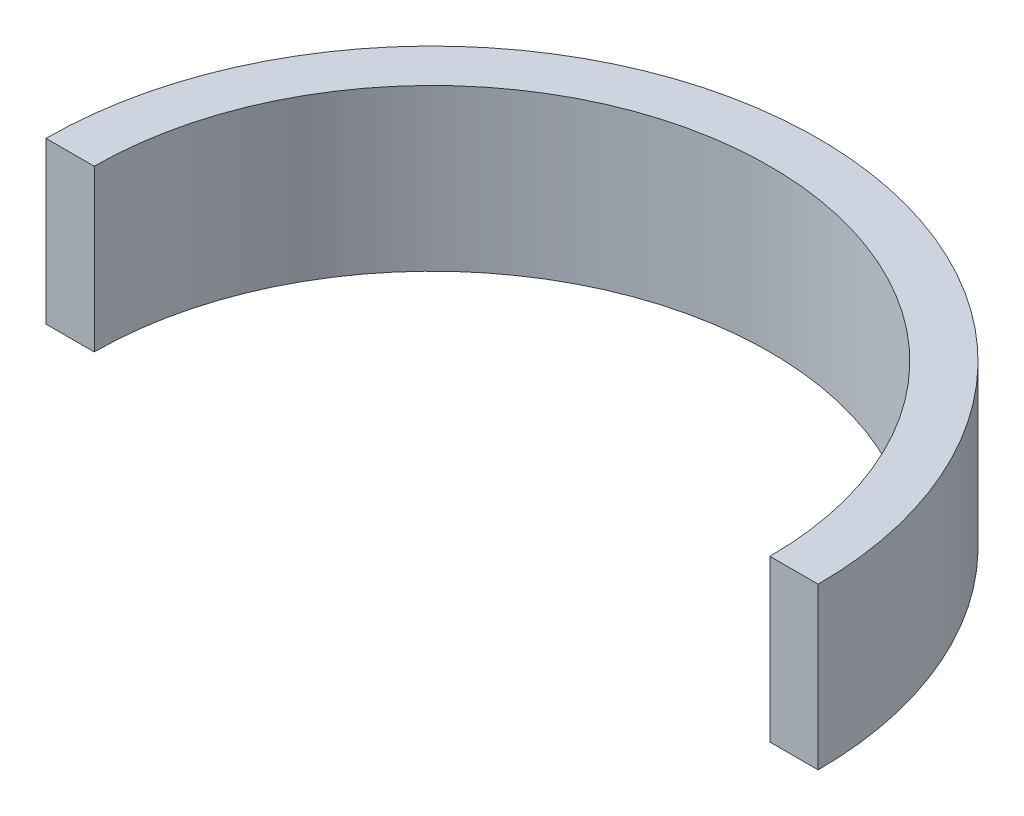
from build123d import *

# Parameters (mm, degrees)
EXTRUDE_1_DEPTH = 20


with BuildPart() as part:
    # 草图1 → 凸台-拉伸1 (new body)
    with BuildSketch(Plane(origin=(0, 0, 0), x_dir=(1, 0, 0), z_dir=(0, 1, 0))):
        with BuildLine():
            Line((42, 0), (48, 0))
            ThreePointArc((48, 0), (0, 48), (-48, 0))
            Line((-48, 0), (-42, 0))
            ThreePointArc((-42, 0), (0, 42), (42, 0))
        make_face()
    extrude(amount=EXTRUDE_1_DEPTH)


solid = part.part
